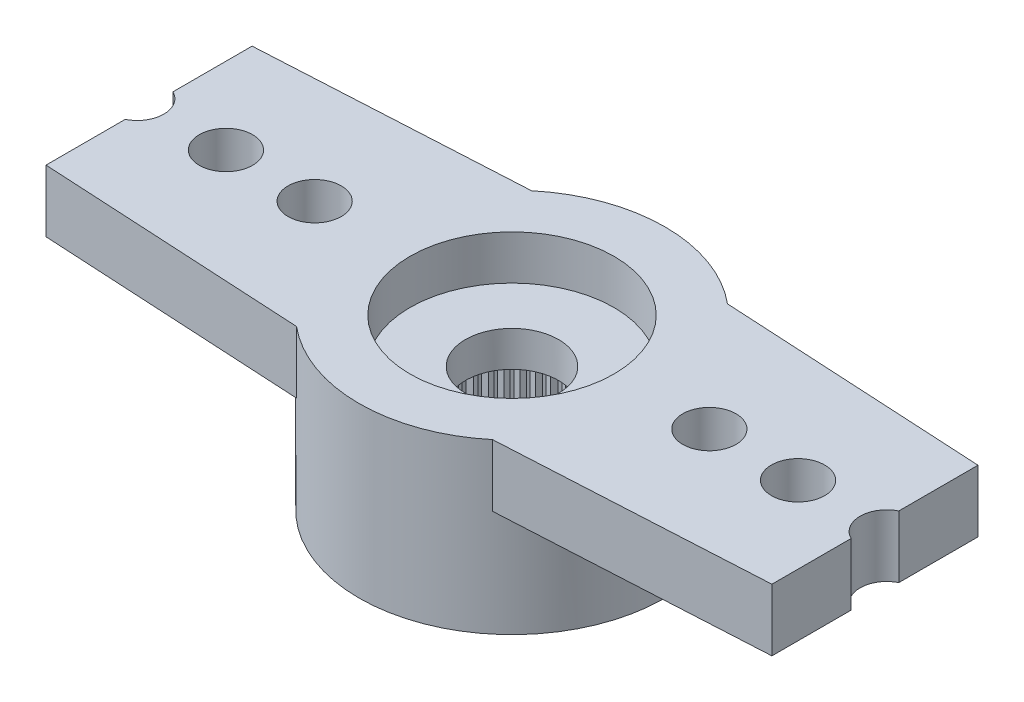
from build123d import *

# Parameters (mm, degrees)
RESSALTO_EXTRUS_O1_DEPTH   = 1.4
ESBO_O2_R                  = 3.45
RESSALTO_EXTRUS_O2_DEPTH   = 2.4
FURO4_D                    = 1.2
PADR_O_LINEAR1_COUNT       = 6
PADR_O_LINEAR1_PITCH       = 2
PADR_OCIRCULAR2_COUNT      = 2
PADR_OCIRCULAR2_COPY_1_D   = 1.2
PADR_OCIRCULAR2_COPY_2_D   = 1.2
PADR_OCIRCULAR2_COPY_3_D   = 1.2
PADR_OCIRCULAR2_COPY_4_D   = 1.2
PADR_OCIRCULAR2_COPY_5_D   = 1.2
FURO1_D                    = 4.95
FURO1_DEPTH                = 2
FURO2_D                    = 4.6
FURO2_DEPTH                = 1
FURO3_D                    = 2.1
RESSALTO_EXTRUS_O3_DEPTH   = 2
PADR_OCIRCULAR1_COUNT      = 60
SZKIC1_R                   = 0.6
WYTNIJ_WYCI_GNI_CIE1_DEPTH = 4.8


with BuildPart() as part:
    # Esboço1 → Ressalto-extrusão1 (new body)
    with BuildSketch(Plane(origin=(0, 0, 0), x_dir=(1, 0, 0), z_dir=(0, 1, 0))):
        with BuildLine():
            Line((-14.159121967, 1.99702088), (-2.209072203, 2.65))
            ThreePointArc((-2.209072203, 2.65), (3.45, 0), (-2.209072203, -2.65))
            Line((-2.209072203, -2.65), (-14.159121967, -1.99702088))
            ThreePointArc((-14.159121967, -1.99702088), (-16.05, 0), (-14.159121967, 1.99702088))
        make_face()
    ressalto_extrus_o1 = extrude(amount=-RESSALTO_EXTRUS_O1_DEPTH)

    # Esboço2 → Ressalto-extrusão2 (add)
    with BuildSketch(Plane.XZ.offset(1.4)):
        Circle(ESBO_O2_R)
    extrude(amount=RESSALTO_EXTRUS_O2_DEPTH)

    # Furo4 (through all)
    with Locations(Plane(origin=(0, 0, 0), x_dir=(1, 0, 0), z_dir=(0, 1, 0))):
        with Locations((-14.45, 0)):
            furo4 = Hole(FURO4_D / 2)

    # Padrão linear1: Furo4 ×6
    with Locations(*[(i * PADR_O_LINEAR1_PITCH, 0, 0) for i in range(1, PADR_O_LINEAR1_COUNT)]):
        add(furo4, mode=Mode.SUBTRACT)

    # PadrãoCircular2: Ressalto-extrusão1, Furo4 ×2 about axis
    padr_ocircular2_axis = Axis((0, 0, 0), (0, 1, 0))
    for i in range(1, PADR_OCIRCULAR2_COUNT):
        add(ressalto_extrus_o1.rotate(padr_ocircular2_axis, i * 360 / PADR_OCIRCULAR2_COUNT))
        add(furo4.rotate(padr_ocircular2_axis, i * 360 / PADR_OCIRCULAR2_COUNT), mode=Mode.SUBTRACT)

    # PadrãoCircular2 copy 1 (through all)
    with Locations(Plane(origin=(-2, 0, 0), x_dir=(-1, 0, 0), z_dir=(0, 1, 0))):
        with Locations((-14.45, 0)):
            Hole(PADR_OCIRCULAR2_COPY_1_D / 2)

    # PadrãoCircular2 copy 2 (through all)
    with Locations(Plane(origin=(-4, 0, 0), x_dir=(-1, 0, 0), z_dir=(0, 1, 0))):
        with Locations((-14.45, 0)):
            Hole(PADR_OCIRCULAR2_COPY_2_D / 2)

    # PadrãoCircular2 copy 3 (through all)
    with Locations(Plane(origin=(-6, 0, 0), x_dir=(-1, 0, 0), z_dir=(0, 1, 0))):
        with Locations((-14.45, 0)):
            Hole(PADR_OCIRCULAR2_COPY_3_D / 2)

    # PadrãoCircular2 copy 4 (through all)
    with Locations(Plane(origin=(-8, 0, 0), x_dir=(-1, 0, 0), z_dir=(0, 1, 0))):
        with Locations((-14.45, 0)):
            Hole(PADR_OCIRCULAR2_COPY_4_D / 2)

    # PadrãoCircular2 copy 5 (through all)
    with Locations(Plane(origin=(-10, 0, 0), x_dir=(-1, 0, 0), z_dir=(0, 1, 0))):
        with Locations((-14.45, 0)):
            Hole(PADR_OCIRCULAR2_COPY_5_D / 2)

    # Furo1
    with Locations(Plane(origin=(0, -3.8, 0), x_dir=(-1, 0, 0), z_dir=(0, -1, 0))):
        with Locations((0, 0)):
            Hole(FURO1_D / 2, depth=FURO1_DEPTH)

    # Furo2
    with Locations(Plane(origin=(0, 0, 0), x_dir=(1, 0, 0), z_dir=(0, 1, 0))):
        with Locations((0, 0)):
            Hole(FURO2_D / 2, depth=FURO2_DEPTH)

    # Furo3 (through all)
    with Locations(Plane(origin=(0, 0, 0), x_dir=(1, 0, 0), z_dir=(0, 1, 0))):
        with Locations((0, 0)):
            Hole(FURO3_D / 2)

    # Esboço11 → Ressalto-extrusão3 (add)
    with BuildSketch(Plane.XZ.offset(3.8)):
        with BuildLine():
            Line((-0.098056786, 2.473056786), (0, 2.375))
            Line((0, 2.375), (0.098056786, 2.473056786))
            ThreePointArc((0.098056786, 2.473056786), (0, 2.475), (-0.098056786, 2.473056786))
        make_face()
    ressalto_extrus_o3 = extrude(amount=-RESSALTO_EXTRUS_O3_DEPTH)

    # PadrãoCircular1: Ressalto-extrusão3 ×60 about axis
    padr_ocircular1_axis = Axis((0, 0, 0), (0, 1, 0))
    for i in range(1, PADR_OCIRCULAR1_COUNT):
        add(ressalto_extrus_o3.rotate(padr_ocircular1_axis, i * 360 / PADR_OCIRCULAR1_COUNT))

    # Szkic1 → Wytnij-wyciągnięcie1 (cut, through all)
    with BuildSketch(Plane(origin=(0, 0, 0), x_dir=(1, 0, 0), z_dir=(0, 1, 0))):
        with BuildLine():
            Line((-8.184097085, 0.537862101), (-8.184097085, 2.32351044))
            Line((-8.184097085, 2.32351044), (-14.159121967, 1.99702088))
            ThreePointArc((-14.159121967, 1.99702088), (-16.05, 0), (-14.159121967, -1.99702088))
            Line((-14.159121967, -1.99702088), (-8.184097085, -2.32351044))
            Line((-8.184097085, -2.32351044), (-8.184097085, -0.537862101))
            ThreePointArc((-8.184097085, -0.537862101), (-9.05, 0), (-8.184097085, 0.537862101))
        make_face()
        with Locations((-14.45, 0)):
            Circle(SZKIC1_R, mode=Mode.SUBTRACT)
        with Locations((-12.45, 0)):
            Circle(SZKIC1_R, mode=Mode.SUBTRACT)
        with Locations((-10.45, 0)):
            Circle(SZKIC1_R, mode=Mode.SUBTRACT)
        with BuildLine():
            Line((14.159121967, 1.99702088), (8.184097085, 2.32351044))
            Line((8.184097085, 2.32351044), (8.184097085, 0.537862101))
            ThreePointArc((8.184097085, 0.537862101), (8.766589838, 0.509677226), (9.05, 0))
            ThreePointArc((9.05, 0), (8.766589838, -0.509677226), (8.184097085, -0.537862101))
            Line((8.184097085, -0.537862101), (8.184097085, -2.32351044))
            Line((8.184097085, -2.32351044), (14.159121967, -1.99702088))
            ThreePointArc((14.159121967, -1.99702088), (16.05, 0), (14.159121967, 1.99702088))
        make_face()
        with Locations((10.45, 0)):
            Circle(SZKIC1_R, mode=Mode.SUBTRACT)
        with Locations((12.45, 0)):
            Circle(SZKIC1_R, mode=Mode.SUBTRACT)
        with Locations((14.45, 0)):
            Circle(SZKIC1_R, mode=Mode.SUBTRACT)
    extrude(amount=-WYTNIJ_WYCI_GNI_CIE1_DEPTH, mode=Mode.SUBTRACT)


solid = part.part
